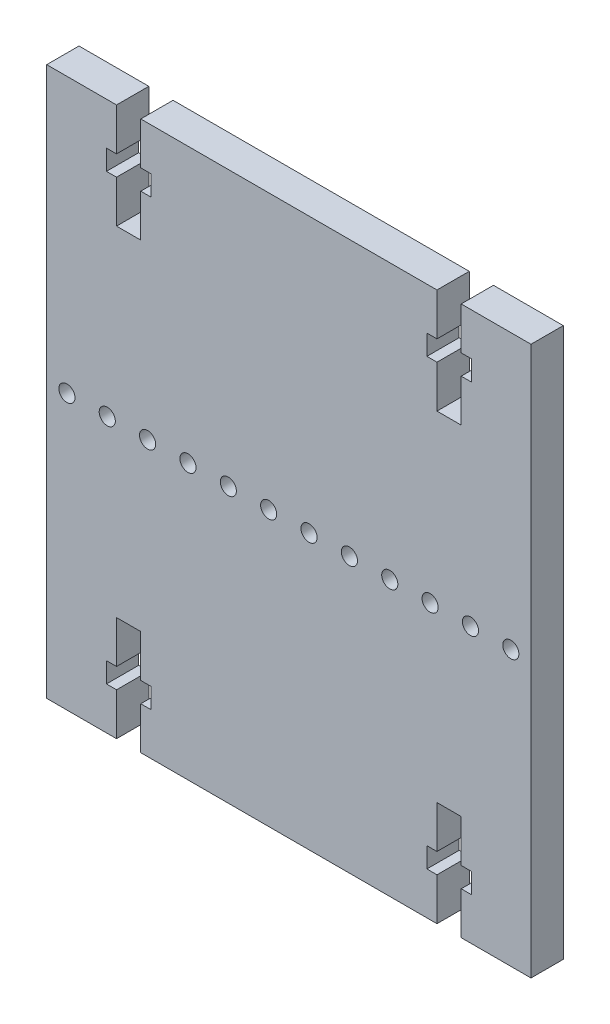
from build123d import *

# Parameters (mm, degrees)
SKETCH_2_W          = 60
SKETCH_2_H          = 68
EXTRUDE_1_DEPTH     = 4
CUT_EXTRUDE_1_DEPTH = 4
SKETCH_4_R          = 1
CUT_EXTRUDE_2_DEPTH = 4


with BuildPart() as part:
    # Эскиз2 → Бобышка-Вытянуть1 (new body)
    with BuildSketch(Plane.XY):
        with Locations((30, 34)):
            Rectangle(SKETCH_2_W, SKETCH_2_H)
    extrude(amount=EXTRUDE_1_DEPTH)

    # Эскиз3 → Вырез-Вытянуть1 (cut)
    with BuildSketch(Plane.XY.offset(4)):
        Polygon((8.65, 0), (8.65, 5.25), (7.4, 5.25), (7.4, 7.75), (8.65, 7.75), (8.65, 13), (11.65, 13), (11.65, 7.75), (12.9, 7.75), (12.9, 5.25), (11.65, 5.25), (11.65, 0), align=None)
        Polygon((47.1, 7.75), (48.35, 7.75), (48.35, 13), (51.35, 13), (51.35, 7.75), (52.6, 7.75), (52.6, 5.25), (51.35, 5.25), (51.35, 0), (48.35, 0), (48.35, 5.25), (47.1, 5.25), align=None)
        Polygon((48.35, 68), (48.35, 62.75), (47.1, 62.75), (47.1, 60.25), (48.35, 60.25), (48.35, 55), (51.35, 55), (51.35, 60.25), (52.6, 60.25), (52.6, 62.75), (51.35, 62.75), (51.35, 68), align=None)
        Polygon((8.65, 68), (8.65, 62.75), (7.4, 62.75), (7.4, 60.25), (8.65, 60.25), (8.65, 55), (11.65, 55), (11.65, 60.25), (12.9, 60.25), (12.9, 62.75), (11.65, 62.75), (11.65, 68), align=None)
    extrude(amount=-CUT_EXTRUDE_1_DEPTH, mode=Mode.SUBTRACT)

    # Эскиз4 → Вырез-Вытянуть2 (cut)
    with BuildSketch(Plane.XY.offset(4)):
        with Locations((2.5, 34)):
            Circle(SKETCH_4_R)
        with Locations((7.5, 34)):
            Circle(SKETCH_4_R)
        with Locations((12.5, 34)):
            Circle(SKETCH_4_R)
        with Locations((17.5, 34)):
            Circle(SKETCH_4_R)
        with Locations((22.5, 34)):
            Circle(SKETCH_4_R)
        with Locations((27.5, 34)):
            Circle(SKETCH_4_R)
        with Locations((32.5, 34)):
            Circle(SKETCH_4_R)
        with Locations((37.5, 34)):
            Circle(SKETCH_4_R)
        with Locations((42.5, 34)):
            Circle(SKETCH_4_R)
        with Locations((47.5, 34)):
            Circle(SKETCH_4_R)
        with Locations((52.5, 34)):
            Circle(SKETCH_4_R)
        with Locations((57.5, 34)):
            Circle(SKETCH_4_R)
    extrude(amount=-CUT_EXTRUDE_2_DEPTH, mode=Mode.SUBTRACT)


solid = part.part
